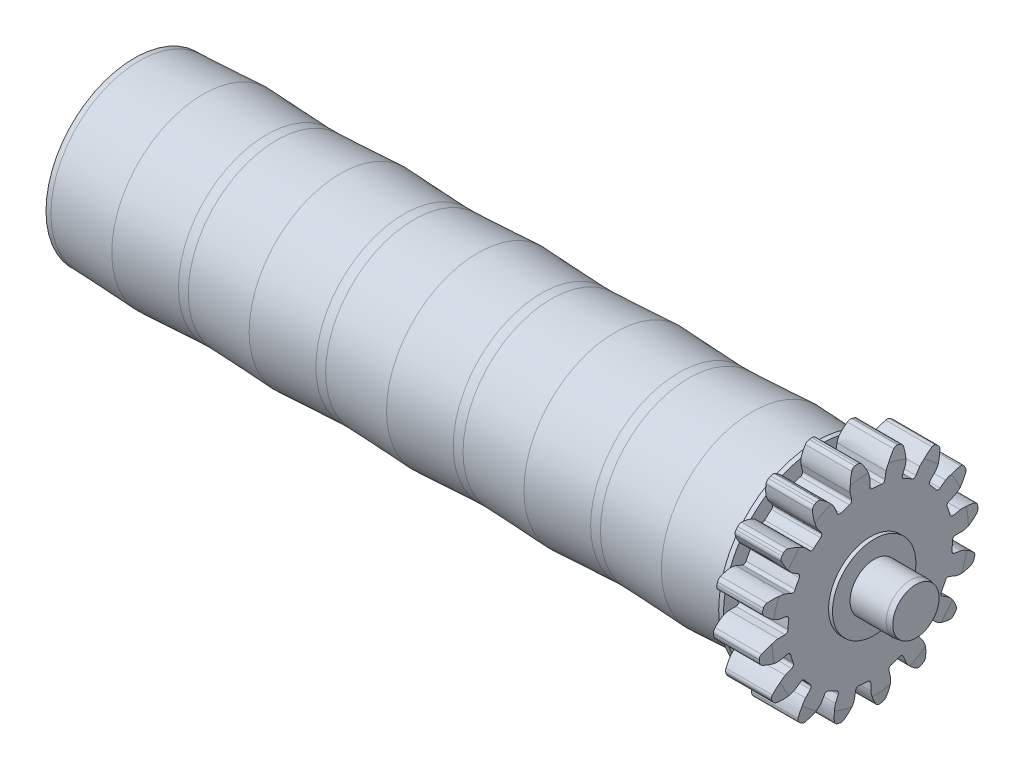
from build123d import *

# Parameters (mm, degrees)
SKETCH1_R                = 20
BOSS_EXTRUDE1_DEPTH      = 150
SKETCH1_3_R              = 8.5
BOSS_EXTRUDE2_DEPTH      = 0.8
BOSS_EXTRUDE3_START      = -0.8
SKETCH1_4_R              = 4.925
BOSS_EXTRUDE3_DEPTH      = 8.5
BOSS_EXTRUDE4_START      = 150
SKETCH1_9_R              = 8.5
SKETCH1_9_R_2            = 4.925
BOSS_EXTRUDE4_DEPTH      = 0.8
BOSS_EXTRUDE5_START      = 150.8
SKETCH1_10_R             = 4.925
BOSS_EXTRUDE5_DEPTH      = 8.5
SKETCH2_W                = 1
SKETCH2_H                = 2
SKETCH3_R                = 22.5
BOSS_EXTRUDE6_DEPTH      = 10
CUT_EXTRUDE3_DEPTH       = 10
FILLET1_R                = 0.5
FILLET2_R                = 1
CIRPATTERN1_COUNT        = 16
FILLET1_OF_CIRPATTERN1_R = 0.5
FILLET2_OF_CIRPATTERN1_R = 1
SKETCH4_OUTSIDE_W        = 82.798
SKETCH4_OUTSIDE_H        = 82.798
CUT_EXTRUDE4_DEPTH       = 10
CHAMFER1_SIZE            = 0.2
CHAMFER1_SIZE2           = 1.134256364
CHAMFER2_SIZE            = 0.2
CHAMFER2_SIZE2           = 1.134256364


with BuildPart() as part:
    # Sketch1 → Boss-Extrude1 (new body)
    with BuildSketch(Plane(origin=(0, 0, 0), x_dir=(0, 0, -1), z_dir=(1, 0, 0))):
        Circle(SKETCH1_R)
    extrude(amount=BOSS_EXTRUDE1_DEPTH)

    # Sketch1_3 → Boss-Extrude2 (add)
    with BuildSketch(Plane(origin=(0, 0, 0), x_dir=(0, 0, -1), z_dir=(1, 0, 0))):
        Circle(SKETCH1_3_R)
    extrude(amount=-BOSS_EXTRUDE2_DEPTH)

    # Sketch1_4 → Boss-Extrude3 (add)
    with BuildSketch(Plane(origin=(0, 0, 0), x_dir=(0, 0, -1), z_dir=(1, 0, 0)).offset(BOSS_EXTRUDE3_START)):
        Circle(SKETCH1_4_R)
    extrude(amount=-BOSS_EXTRUDE3_DEPTH)

    # Sketch1_9 → Boss-Extrude4 (add)
    with BuildSketch(Plane(origin=(0, 0, 0), x_dir=(0, 0, -1), z_dir=(1, 0, 0)).offset(BOSS_EXTRUDE4_START)):
        Circle(SKETCH1_9_R)
        Circle(SKETCH1_9_R_2, mode=Mode.SUBTRACT)
        Circle(SKETCH1_9_R_2)
        with BuildLine():
            ThreePointArc((1.823321146, -2.42), (0, 3.03), (-1.823321146, -2.42))
            ThreePointArc((-1.823321146, -2.42), (0, -3.03), (1.823321146, -2.42))
        make_face(mode=Mode.SUBTRACT)
        with BuildLine():
            Line((-1.823321146, -2.42), (1.823321146, -2.42))
            ThreePointArc((1.823321146, -2.42), (0, 3.03), (-1.823321146, -2.42))
        make_face()
        with BuildLine():
            ThreePointArc((1.823321146, -2.42), (0, -3.03), (-1.823321146, -2.42))
            Line((-1.823321146, -2.42), (1.823321146, -2.42))
        make_face()
    extrude(amount=BOSS_EXTRUDE4_DEPTH)

    # Sketch1_10 → Boss-Extrude5 (add)
    with BuildSketch(Plane(origin=(0, 0, 0), x_dir=(0, 0, -1), z_dir=(1, 0, 0)).offset(BOSS_EXTRUDE5_START)):
        Circle(SKETCH1_10_R)
    extrude(amount=BOSS_EXTRUDE5_DEPTH)

    # Sketch2 → Cut-Revolve1 (revolve, cut)
    with BuildSketch(Plane.XY, mode=Mode.PRIVATE) as cut_revolve1_sk:
        Polygon((27, 20), (1, 20), (1, 18), (14, 18.6), (27, 18), align=None)
        Polygon((27, 18), (27, 20), (28, 20), (29, 20), (29, 18), align=None)
        Polygon((29, 20), (29, 18), (42, 18.6), (55, 18), (55, 20), align=None)
        Polygon((55, 18), (55, 20), (56, 20), (57, 20), (57, 18), align=None)
        Polygon((57, 20), (57, 18), (70, 18.6), (83, 18), (83, 20), align=None)
        Polygon((83, 18), (83, 20), (84, 20), (85, 20), (85, 18), align=None)
        Polygon((85, 20), (85, 18), (98, 18.6), (111, 18), (111, 20), align=None)
        Polygon((111, 18), (111, 20), (112, 20), (113, 20), (113, 18), align=None)
        Polygon((113, 20), (113, 18), (126, 18.6), (139, 18), (139, 19.9), (139, 20), align=None)
        Polygon((140, 20), (139, 20), (139, 19.9), (150, 19.9), (150, 20), align=None)
        with Locations((0.5, 19)):
            Rectangle(SKETCH2_W, SKETCH2_H)
    revolve(cut_revolve1_sk.sketch.rotate(Axis((0, 0, 0), (1, 0, 0)), 90), axis=Axis((0, 0, 0), (1, 0, 0)), mode=Mode.SUBTRACT)  # turned: the seam where the file's is

    # Sketch3 → Boss-Extrude6 (add)
    with BuildSketch(Plane(origin=(150, 0, 0), x_dir=(0, 0, -1), z_dir=(1, 0, 0))):
        Circle(SKETCH3_R)
    extrude(amount=-BOSS_EXTRUDE6_DEPTH)

    # Sketch3_3 → Cut-Extrude3 (cut)
    with BuildSketch(Plane(origin=(150, 0, 0), x_dir=(0, 0, -1), z_dir=(1, 0, 0))):
        with BuildLine():
            Line((18.793852416, 0), (16.875, 0))
            ThreePointArc((16.875, 0), (16.816528534, -1.403564417), (16.641519339, -2.797402201))
            Line((16.641519339, -2.797402201), (18.533822722, -3.11549417))
            add(Edge.make_bspline(
                [(18.533822722, -3.11549417), (18.540143259, -3.116650367), (18.557818877, -3.120174741), (18.59102423, -3.127948355), (18.644868838, -3.14220254), (18.712949139, -3.162664487), (18.800284389, -3.191738795), (18.902266481, -3.229352045), (19.01333304, -3.274191401), (19.133012214, -3.326732031), (19.251334581, -3.382453012), (19.368317547, -3.441093179), (19.483872699, -3.502252085), (19.622639053, -3.579554465), (19.787320314, -3.676709438), (19.977176405, -3.796702318), (20.189293185, -3.940335966), (20.401861332, -4.094683446), (20.60799726, -4.25307101), (20.812611431, -4.420472139), (21.00798126, -4.587659246), (21.20695704, -4.768722867), (21.388624735, -4.939634627), (21.58456819, -5.136136858), (21.702177554, -5.256735347), (21.796059885, -5.357369907), (21.840902155, -5.406014525)],
                knots=[0, 0, 0, 0, 0, 0.005376749, 0.015083688, 0.02853182, 0.04661014, 0.064854849, 0.092110525, 0.119476176, 0.146842496, 0.174208854, 0.201574956, 0.228941013, 0.256307345, 0.307035032, 0.361767352, 0.416499661, 0.471231937, 0.525964282, 0.580696616, 0.635428982, 0.690161387, 0.744893688, 0.799626082, 0.851029126, 0.851029126, 0.851029126, 0.851029126, 0.851029126], degree=4))
            ThreePointArc((21.840902155, -5.406014525), (22.334617732, -2.723022357), (22.5, 0))
            ThreePointArc((22.5, 0), (22.483713995, 0.855923463), (22.434879558, 1.710607852))
            add(Edge.make_bspline(
                [(18.793852416, 0), (18.800277167, 9.2432e-05), (18.81829247, 0.000637921), (18.852327044, 0.002799463), (18.907789609, 0.007930502), (18.978319976, 0.016823532), (19.06926657, 0.031017834), (19.176072873, 0.051204897), (19.293035835, 0.077012138), (19.419768906, 0.108986367), (19.545691155, 0.144321865), (19.670776454, 0.182758195), (19.79487123, 0.223915106), (19.944532197, 0.277144366), (20.123040519, 0.345655574), (20.33016124, 0.432515425), (20.563153629, 0.538998755), (20.798367194, 0.655972857), (21.027907269, 0.777997426), (21.257440837, 0.909163115), (21.477822489, 1.041650195), (21.704060536, 1.187224031), (21.911547079, 1.32565566), (22.137354045, 1.486957173), (22.27332803, 1.586390737), (22.382593806, 1.670069867), (22.434879558, 1.710607852)],
                knots=[0, 0, 0, 0, 0, 0.005376749, 0.015083688, 0.02853182, 0.04661014, 0.064854849, 0.092110525, 0.119476176, 0.146842496, 0.174208854, 0.201574956, 0.228941013, 0.256307345, 0.307035032, 0.361767352, 0.416499661, 0.471231937, 0.525964282, 0.580696616, 0.635428982, 0.690161387, 0.744893688, 0.799626082, 0.851029126, 0.851029126, 0.851029126, 0.851029126, 0.851029126], degree=4))
        make_face()
        with BuildLine():
            Line((18.793852416, 0), (16.875, 0))
            ThreePointArc((16.875, 0), (16.816528534, -1.403564417), (16.641519339, -2.797402201))
            Line((16.641519339, -2.797402201), (18.533822722, -3.11549417))
            add(Edge.make_bspline(
                [(18.533822722, -3.11549417), (18.540143259, -3.116650367), (18.557818877, -3.120174741), (18.59102423, -3.127948355), (18.644868838, -3.14220254), (18.712949139, -3.162664487), (18.800284389, -3.191738795), (18.902266481, -3.229352045), (19.01333304, -3.274191401), (19.133012214, -3.326732031), (19.251334581, -3.382453012), (19.368317547, -3.441093179), (19.483872699, -3.502252085), (19.622639053, -3.579554465), (19.787320314, -3.676709438), (19.977176405, -3.796702318), (20.189293185, -3.940335966), (20.401861332, -4.094683446), (20.60799726, -4.25307101), (20.812611431, -4.420472139), (21.00798126, -4.587659246), (21.20695704, -4.768722867), (21.388624735, -4.939634627), (21.58456819, -5.136136858), (21.702177554, -5.256735347), (21.796059885, -5.357369907), (21.840902155, -5.406014525)],
                knots=[0, 0, 0, 0, 0, 0.005376749, 0.015083688, 0.02853182, 0.04661014, 0.064854849, 0.092110525, 0.119476176, 0.146842496, 0.174208854, 0.201574956, 0.228941013, 0.256307345, 0.307035032, 0.361767352, 0.416499661, 0.471231937, 0.525964282, 0.580696616, 0.635428982, 0.690161387, 0.744893688, 0.799626082, 0.851029126, 0.851029126, 0.851029126, 0.851029126, 0.851029126], degree=4))
            ThreePointArc((21.840902155, -5.406014525), (22.334617732, -2.723022357), (22.5, 0))
            ThreePointArc((22.5, 0), (22.483713995, 0.855923463), (22.434879558, 1.710607852))
            add(Edge.make_bspline(
                [(18.793852416, 0), (18.800277167, 9.2432e-05), (18.81829247, 0.000637921), (18.852327044, 0.002799463), (18.907789609, 0.007930502), (18.978319976, 0.016823532), (19.06926657, 0.031017834), (19.176072873, 0.051204897), (19.293035835, 0.077012138), (19.419768906, 0.108986367), (19.545691155, 0.144321865), (19.670776454, 0.182758195), (19.79487123, 0.223915106), (19.944532197, 0.277144366), (20.123040519, 0.345655574), (20.33016124, 0.432515425), (20.563153629, 0.538998755), (20.798367194, 0.655972857), (21.027907269, 0.777997426), (21.257440837, 0.909163115), (21.477822489, 1.041650195), (21.704060536, 1.187224031), (21.911547079, 1.32565566), (22.137354045, 1.486957173), (22.27332803, 1.586390737), (22.382593806, 1.670069867), (22.434879558, 1.710607852)],
                knots=[0, 0, 0, 0, 0, 0.005376749, 0.015083688, 0.02853182, 0.04661014, 0.064854849, 0.092110525, 0.119476176, 0.146842496, 0.174208854, 0.201574956, 0.228941013, 0.256307345, 0.307035032, 0.361767352, 0.416499661, 0.471231937, 0.525964282, 0.580696616, 0.635428982, 0.690161387, 0.744893688, 0.799626082, 0.851029126, 0.851029126, 0.851029126, 0.851029126, 0.851029126], degree=4))
        make_face()
    cut_extrude3 = extrude(amount=-CUT_EXTRUDE3_DEPTH, mode=Mode.SUBTRACT)

    # Fillet1
    fillet1_edges = [part.edges().sort_by_distance(p)[0] for p in [
        (145, -2.797402201, -16.641519339),
        (145, 0, -16.875),
    ]]
    fillet(fillet1_edges, radius=FILLET1_R)

    # Fillet2
    fillet2_edges = [part.edges().sort_by_distance(p)[0] for p in [
        (145, 1.710607852, -22.434879558),
        (145, -5.406014525, -21.840902155),
    ]]
    fillet(fillet2_edges, radius=FILLET2_R)

    # CirPattern1: Cut-Extrude3 ×16 about axis
    cirpattern1_axis = Axis((126, 0, 0), (-1, 0, 0))
    for i in range(1, CIRPATTERN1_COUNT):
        add(cut_extrude3.rotate(cirpattern1_axis, i * 360 / CIRPATTERN1_COUNT), mode=Mode.SUBTRACT)

    # Fillet1 of CirPattern1
    fillet1_of_cirpattern1_edges = [part.edges().sort_by_distance(p)[0] for p in [
        (145, -8.952896379, -14.304239631),
        (145, -6.457782921, -15.590467111),
        (145, -13.74539324, -9.789269108),
        (145, -11.932426933, -11.932426933),
        (145, -16.445278584, -3.783971103),
        (145, -15.590467111, -6.457782921),
        (145, -16.641519339, 2.797402201),
        (145, -16.875, 0),
        (145, -14.304239631, 8.952896379),
        (145, -15.590467111, 6.457782921),
        (145, -9.789269108, 13.74539324),
        (145, -11.932426933, 11.932426933),
        (145, -3.783971103, 16.445278584),
        (145, -6.457782921, 15.590467111),
        (145, 2.797402201, 16.641519339),
        (145, 0, 16.875),
        (145, 8.952896379, 14.304239631),
        (145, 6.457782921, 15.590467111),
        (145, 13.74539324, 9.789269108),
        (145, 11.932426933, 11.932426933),
        (145, 16.445278584, 3.783971103),
        (145, 15.590467111, 6.457782921),
        (145, 16.641519339, -2.797402201),
        (145, 16.875, 0),
        (145, 14.304239631, -8.952896379),
        (145, 15.590467111, -6.457782921),
        (145, 9.789269108, -13.74539324),
        (145, 11.932426933, -11.932426933),
        (145, 3.783971103, -16.445278584),
        (145, 6.457782921, -15.590467111),
    ]]
    fillet(fillet1_of_cirpattern1_edges, radius=FILLET1_OF_CIRPATTERN1_R)

    # Fillet2 of CirPattern1
    fillet2_of_cirpattern1_edges = [part.edges().sort_by_distance(p)[0] for p in [
        (145, -7.005061131, -21.381747322),
        (145, -13.352657575, -18.109570279),
        (145, -14.654273058, -17.073437883),
        (145, -19.266479551, -11.621220491),
        (145, -20.072504754, -10.165852297),
        (145, -22.247154667, -3.36364523),
        (145, -22.434879558, -1.710607852),
        (145, -21.840902155, 5.406014525),
        (145, -21.381747322, 7.005061131),
        (145, -18.109570279, 13.352657575),
        (145, -17.073437883, 14.654273058),
        (145, -11.621220491, 19.266479551),
        (145, -10.165852297, 20.072504754),
        (145, -3.36364523, 22.247154667),
        (145, -1.710607852, 22.434879558),
        (145, 5.406014525, 21.840902155),
        (145, 7.005061131, 21.381747322),
        (145, 13.352657575, 18.109570279),
        (145, 14.654273058, 17.073437883),
        (145, 19.266479551, 11.621220491),
        (145, 20.072504754, 10.165852297),
        (145, 22.247154667, 3.36364523),
        (145, 22.434879558, 1.710607852),
        (145, 21.840902155, -5.406014525),
        (145, 21.381747322, -7.005061131),
        (145, 18.109570279, -13.352657575),
        (145, 17.073437883, -14.654273058),
        (145, 11.621220491, -19.266479551),
        (145, 10.165852297, -20.072504754),
        (145, 3.36364523, -22.247154667),
    ]]
    fillet(fillet2_of_cirpattern1_edges, radius=FILLET2_OF_CIRPATTERN1_R)

    # Sketch4 outside → Cut-Extrude4 (cut)
    with BuildSketch(Plane(origin=(150, 0, 0), x_dir=(0, 0, -1), z_dir=(1, 0, 0))):
        Rectangle(SKETCH4_OUTSIDE_W, SKETCH4_OUTSIDE_H)
        with BuildLine():
            Line((16.084027229, -6.553982996), (17.400825548, -7.099418718))
            add(Edge.make_bspline(
                [(17.400825548, -7.099418718), (17.468205114, -7.126079363), (17.53735939, -7.143460734), (17.675930951, -7.176848305), (17.745707701, -7.190975003), (17.956070336, -7.22795715), (18.097788211, -7.245382593), (18.52533898, -7.282064664), (18.810706139, -7.285520422), (19.667508071, -7.251758438), (20.232380272, -7.171231176), (20.790500392, -7.047676668)],
                knots=[0, 0, 0, 0, 0.0625, 0.0625, 0.125, 0.125, 0.25, 0.25, 0.5, 0.5, 1, 1, 1, 1], degree=3))
            ThreePointArc((20.790500392, -7.047676668), (21.208669056, -6.828194438), (21.458128433, -6.427186333))
            ThreePointArc((21.458128433, -6.427186333), (21.529993052, -6.182184014), (21.599060408, -5.936378481))
            ThreePointArc((21.599060408, -5.936378481), (21.600355656, -5.464111816), (21.362335917, -5.056209764))
            add(Edge.make_bspline(
                [(21.362335917, -5.056209764), (20.954562332, -4.655146223), (20.516130086, -4.285439291), (19.808296094, -3.802964384), (19.563276919, -3.653961081), (19.184028171, -3.459717512), (19.055472444, -3.399677951), (18.858095781, -3.31961644), (18.79155061, -3.294586267), (18.656290761, -3.249300304), (18.588391332, -3.227250414), (18.516500063, -3.213985271)],
                knots=[0, 0, 0, 0, 0.5, 0.5, 0.75, 0.75, 0.875, 0.875, 0.9375, 0.9375, 1, 1, 1, 1], degree=3))
            Line((18.516500063, -3.213985271), (17.11092802, -2.977711752))
            ThreePointArc((17.11092802, -2.977711752), (16.726725338, -2.741072894), (16.616075542, -2.303618583))
            ThreePointArc((16.616075542, -2.303618583), (16.716875031, -1.395246999), (16.768052751, -0.482733813))
            ThreePointArc((16.768052751, -0.482733813), (16.949689277, -0.069674709), (17.367804265, 0.1))
            Line((17.367804265, 0.1), (18.793096495, 0.1))
            add(Edge.make_bspline(
                [(18.793096495, 0.1), (18.865549684, 0.10115382), (18.936091467, 0.111559723), (19.076891767, 0.13374267), (19.146763131, 0.147393709), (19.355265319, 0.193728955), (19.492863991, 0.231863028), (19.901907017, 0.361589809), (20.166874355, 0.467602389), (20.945535972, 0.826678299), (21.436593388, 1.117243022), (21.904946881, 1.444975825)],
                knots=[0, 0, 0, 0, 0.0625, 0.0625, 0.125, 0.125, 0.25, 0.25, 0.5, 0.5, 1, 1, 1, 1], degree=3))
            ThreePointArc((21.904946881, 1.444975825), (22.207292137, 1.807777185), (22.284303392, 2.273724336))
            ThreePointArc((22.284303392, 2.273724336), (22.256939314, 2.527578363), (22.226683526, 2.781103997))
            ThreePointArc((22.226683526, 2.781103997), (22.04715155, 3.217917173), (21.671152627, 3.503683319))
            add(Edge.make_bspline(
                [(21.671152627, 3.503683319), (21.140938586, 3.718169521), (20.59439929, 3.891953432), (19.755810799, 4.066825781), (19.472421503, 4.110722104), (19.047707551, 4.145047549), (18.905961401, 4.151320724), (18.692970927, 4.149755137), (18.621912574, 4.147414267), (18.47961858, 4.137491338), (18.40844956, 4.131878793), (18.336954337, 4.11662259)],
                knots=[0, 0, 0, 0, 0.5, 0.5, 0.75, 0.75, 0.875, 0.875, 0.9375, 0.9375, 1, 1, 1, 1], degree=3))
            Line((18.336954337, 4.11662259), (16.947957134, 3.797021724))
            ThreePointArc((16.947957134, 3.797021724), (16.502442369, 3.868619521), (16.23280877, 4.230430761))
            ThreePointArc((16.23280877, 4.230430761), (15.978316599, 5.108230971), (15.676394969, 5.970868091))
            ThreePointArc((15.676394969, 5.970868091), (15.686134362, 6.421994232), (16.007490542, 6.738758902))
            Line((16.007490542, 6.738758902), (17.324288861, 7.284194625))
            add(Edge.make_bspline(
                [(17.324288861, 7.284194625), (17.390785332, 7.31298725), (17.451975275, 7.349596223), (17.573568743, 7.423972535), (17.63289744, 7.463323064), (17.807796613, 7.585921583), (17.920327932, 7.673809605), (18.248590122, 7.950195511), (18.452818764, 8.149536975), (19.034795893, 8.779260759), (19.377279484, 9.235627096), (19.684563776, 9.717643848)],
                knots=[0, 0, 0, 0, 0.0625, 0.0625, 0.125, 0.125, 0.25, 0.25, 0.5, 0.5, 1, 1, 1, 1], degree=3))
            ThreePointArc((19.684563776, 9.717643848), (19.8250563, 10.168531119), (19.717895167, 10.628481086))
            ThreePointArc((19.717895167, 10.628481086), (19.595468325, 10.852539847), (19.470495562, 11.075188602))
            ThreePointArc((19.470495562, 11.075188602), (19.137468479, 11.410047442), (18.6807328, 11.530172378))
            add(Edge.make_bspline(
                [(18.6807328, 11.530172378), (18.108798583, 11.525427661), (17.537357891, 11.476831525), (16.695682397, 11.317478587), (16.41706643, 11.249585113), (16.011546124, 11.118766696), (15.878189117, 11.070318451), (15.682010702, 10.987364112), (15.617257156, 10.958008575), (15.489591988, 10.89438743), (15.425988215, 10.86196691), (15.365773538, 10.820511979)],
                knots=[0, 0, 0, 0, 0.5, 0.5, 0.75, 0.75, 0.875, 0.875, 0.9375, 0.9375, 1, 1, 1, 1], degree=3))
            Line((15.365773538, 10.820511979), (14.204813408, 9.993693063))
            ThreePointArc((14.204813408, 9.993693063), (13.765812144, 9.889349683), (13.378244014, 10.120435371))
            ThreePointArc((13.378244014, 10.120435371), (12.807204309, 10.834027081), (12.19814816, 11.515459455))
            ThreePointArc((12.19814816, 11.515459455), (12.034507686, 11.935972767), (12.210181492, 12.351602848))
            Line((12.210181492, 12.351602848), (13.218015293, 13.35943665))
            add(Edge.make_bspline(
                [(13.218015293, 13.35943665), (13.26843156, 13.411484664), (13.310954049, 13.468723322), (13.394829183, 13.583969881), (13.434582957, 13.643029139), (13.549252301, 13.823226417), (13.619584394, 13.947488232), (13.817090804, 14.328456016), (13.929488792, 14.590778432), (14.22618069, 15.395280352), (14.367950434, 15.947970667), (14.467384276, 16.510888685)],
                knots=[0, 0, 0, 0, 0.0625, 0.0625, 0.125, 0.125, 0.25, 0.25, 0.5, 0.5, 1, 1, 1, 1], degree=3))
            ThreePointArc((14.467384276, 16.510888685), (14.424635355, 16.981218368), (14.149616146, 17.365147939))
            ThreePointArc((14.149616146, 17.365147939), (13.950764917, 17.525300518), (13.750101149, 17.68317614))
            ThreePointArc((13.750101149, 17.68317614), (13.314279313, 17.865101421), (12.846340745, 17.801297213))
            add(Edge.make_bspline(
                [(12.846340745, 17.801297213), (12.319758153, 17.578043917), (11.810412729, 17.314466056), (11.093787696, 16.845147872), (10.862361815, 16.675800766), (10.537771945, 16.399754405), (10.433106477, 16.303960546), (10.283606506, 16.152246501), (10.235015907, 16.100345412), (10.141415429, 15.992711794), (10.095060001, 15.938419029), (10.055293009, 15.877076507)],
                knots=[0, 0, 0, 0, 0.5, 0.5, 0.75, 0.75, 0.875, 0.875, 0.9375, 0.9375, 1, 1, 1, 1], degree=3))
            Line((10.055293009, 15.877076507), (9.299115607, 14.668915226))
            ThreePointArc((9.299115607, 14.668915226), (8.933461808, 14.404516002), (8.486962881, 14.469695438))
            ThreePointArc((8.486962881, 14.469695438), (7.68631126, 14.910440779), (6.86284387, 15.306926504))
            ThreePointArc((6.86284387, 15.306926504), (6.550736307, 15.632807648), (6.553982996, 16.084027229))
            Line((6.553982996, 16.084027229), (7.099418718, 17.400825548))
            add(Edge.make_bspline(
                [(7.099418718, 17.400825548), (7.126079363, 17.468205114), (7.143460734, 17.53735939), (7.176848305, 17.675930951), (7.190975003, 17.745707701), (7.22795715, 17.956070336), (7.245382593, 18.097788211), (7.282064664, 18.52533898), (7.285520422, 18.810706139), (7.251758438, 19.667508071), (7.171231176, 20.232380272), (7.047676668, 20.790500392)],
                knots=[0, 0, 0, 0, 0.0625, 0.0625, 0.125, 0.125, 0.25, 0.25, 0.5, 0.5, 1, 1, 1, 1], degree=3))
            ThreePointArc((7.047676668, 20.790500392), (6.828194438, 21.208669056), (6.427186333, 21.458128433))
            ThreePointArc((6.427186333, 21.458128433), (6.182184014, 21.529993052), (5.936378481, 21.599060408))
            ThreePointArc((5.936378481, 21.599060408), (5.464111816, 21.600355656), (5.056209764, 21.362335917))
            add(Edge.make_bspline(
                [(5.056209764, 21.362335917), (4.655146223, 20.954562332), (4.285439291, 20.516130086), (3.802964384, 19.808296094), (3.653961081, 19.563276919), (3.459717512, 19.184028171), (3.399677951, 19.055472444), (3.31961644, 18.858095781), (3.294586267, 18.79155061), (3.249300304, 18.656290761), (3.227250414, 18.588391332), (3.213985271, 18.516500063)],
                knots=[0, 0, 0, 0, 0.5, 0.5, 0.75, 0.75, 0.875, 0.875, 0.9375, 0.9375, 1, 1, 1, 1], degree=3))
            Line((3.213985271, 18.516500063), (2.977711752, 17.11092802))
            ThreePointArc((2.977711752, 17.11092802), (2.741072894, 16.726725338), (2.303618583, 16.616075542))
            ThreePointArc((2.303618583, 16.616075542), (1.395246999, 16.716875031), (0.482733813, 16.768052751))
            ThreePointArc((0.482733813, 16.768052751), (0.069674709, 16.949689277), (-0.1, 17.367804265))
            Line((-0.1, 17.367804265), (-0.1, 18.793096495))
            add(Edge.make_bspline(
                [(-0.1, 18.793096495), (-0.10115382, 18.865549684), (-0.111559723, 18.936091467), (-0.13374267, 19.076891767), (-0.147393709, 19.146763131), (-0.193728955, 19.355265319), (-0.231863028, 19.492863991), (-0.361589809, 19.901907017), (-0.467602389, 20.166874355), (-0.826678299, 20.945535972), (-1.117243022, 21.436593388), (-1.444975825, 21.904946881)],
                knots=[0, 0, 0, 0, 0.0625, 0.0625, 0.125, 0.125, 0.25, 0.25, 0.5, 0.5, 1, 1, 1, 1], degree=3))
            ThreePointArc((-1.444975825, 21.904946881), (-1.807777185, 22.207292137), (-2.273724336, 22.284303392))
            ThreePointArc((-2.273724336, 22.284303392), (-2.527578363, 22.256939314), (-2.781103997, 22.226683526))
            ThreePointArc((-2.781103997, 22.226683526), (-3.217917173, 22.04715155), (-3.503683319, 21.671152627))
            add(Edge.make_bspline(
                [(-3.503683319, 21.671152627), (-3.718169521, 21.140938586), (-3.891953432, 20.59439929), (-4.066825781, 19.755810799), (-4.110722104, 19.472421503), (-4.145047549, 19.047707551), (-4.151320724, 18.905961401), (-4.149755137, 18.692970927), (-4.147414267, 18.621912574), (-4.137491338, 18.47961858), (-4.131878793, 18.40844956), (-4.11662259, 18.336954337)],
                knots=[0, 0, 0, 0, 0.5, 0.5, 0.75, 0.75, 0.875, 0.875, 0.9375, 0.9375, 1, 1, 1, 1], degree=3))
            Line((-4.11662259, 18.336954337), (-3.797021724, 16.947957134))
            ThreePointArc((-3.797021724, 16.947957134), (-3.868619521, 16.502442369), (-4.230430761, 16.23280877))
            ThreePointArc((-4.230430761, 16.23280877), (-5.108230971, 15.978316599), (-5.970868091, 15.676394969))
            ThreePointArc((-5.970868091, 15.676394969), (-6.421994232, 15.686134362), (-6.738758902, 16.007490542))
            Line((-6.738758902, 16.007490542), (-7.284194625, 17.324288861))
            add(Edge.make_bspline(
                [(-7.284194625, 17.324288861), (-7.31298725, 17.390785332), (-7.349596223, 17.451975275), (-7.423972535, 17.573568743), (-7.463323064, 17.63289744), (-7.585921583, 17.807796613), (-7.673809605, 17.920327932), (-7.950195511, 18.248590122), (-8.149536975, 18.452818764), (-8.779260759, 19.034795893), (-9.235627096, 19.377279484), (-9.717643848, 19.684563776)],
                knots=[0, 0, 0, 0, 0.0625, 0.0625, 0.125, 0.125, 0.25, 0.25, 0.5, 0.5, 1, 1, 1, 1], degree=3))
            ThreePointArc((-9.717643848, 19.684563776), (-10.168531119, 19.8250563), (-10.628481086, 19.717895167))
            ThreePointArc((-10.628481086, 19.717895167), (-10.852539847, 19.595468325), (-11.075188602, 19.470495562))
            ThreePointArc((-11.075188602, 19.470495562), (-11.410047442, 19.137468479), (-11.530172378, 18.6807328))
            add(Edge.make_bspline(
                [(-11.530172378, 18.6807328), (-11.525427661, 18.108798583), (-11.476831525, 17.537357891), (-11.317478587, 16.695682397), (-11.249585113, 16.41706643), (-11.118766696, 16.011546124), (-11.070318451, 15.878189117), (-10.987364112, 15.682010702), (-10.958008575, 15.617257156), (-10.89438743, 15.489591988), (-10.86196691, 15.425988215), (-10.820511979, 15.365773538)],
                knots=[0, 0, 0, 0, 0.5, 0.5, 0.75, 0.75, 0.875, 0.875, 0.9375, 0.9375, 1, 1, 1, 1], degree=3))
            Line((-10.820511979, 15.365773538), (-9.993693063, 14.204813408))
            ThreePointArc((-9.993693063, 14.204813408), (-9.889349683, 13.765812144), (-10.120435371, 13.378244014))
            ThreePointArc((-10.120435371, 13.378244014), (-10.834027081, 12.807204309), (-11.515459455, 12.19814816))
            ThreePointArc((-11.515459455, 12.19814816), (-11.935972767, 12.034507686), (-12.351602848, 12.210181492))
            Line((-12.351602848, 12.210181492), (-13.35943665, 13.218015293))
            add(Edge.make_bspline(
                [(-13.35943665, 13.218015293), (-13.411484664, 13.26843156), (-13.468723322, 13.310954049), (-13.583969881, 13.394829183), (-13.643029139, 13.434582957), (-13.823226417, 13.549252301), (-13.947488232, 13.619584394), (-14.328456016, 13.817090804), (-14.590778432, 13.929488792), (-15.395280352, 14.22618069), (-15.947970667, 14.367950434), (-16.510888685, 14.467384276)],
                knots=[0, 0, 0, 0, 0.0625, 0.0625, 0.125, 0.125, 0.25, 0.25, 0.5, 0.5, 1, 1, 1, 1], degree=3))
            ThreePointArc((-16.510888685, 14.467384276), (-16.981218368, 14.424635355), (-17.365147939, 14.149616146))
            ThreePointArc((-17.365147939, 14.149616146), (-17.525300518, 13.950764917), (-17.68317614, 13.750101149))
            ThreePointArc((-17.68317614, 13.750101149), (-17.865101421, 13.314279313), (-17.801297213, 12.846340745))
            add(Edge.make_bspline(
                [(-17.801297213, 12.846340745), (-17.578043917, 12.319758153), (-17.314466056, 11.810412729), (-16.845147872, 11.093787696), (-16.675800766, 10.862361815), (-16.399754405, 10.537771945), (-16.303960546, 10.433106477), (-16.152246501, 10.283606506), (-16.100345412, 10.235015907), (-15.992711794, 10.141415429), (-15.938419029, 10.095060001), (-15.877076507, 10.055293009)],
                knots=[0, 0, 0, 0, 0.5, 0.5, 0.75, 0.75, 0.875, 0.875, 0.9375, 0.9375, 1, 1, 1, 1], degree=3))
            Line((-15.877076507, 10.055293009), (-14.668915226, 9.299115607))
            ThreePointArc((-14.668915226, 9.299115607), (-14.404516002, 8.933461808), (-14.469695438, 8.486962881))
            ThreePointArc((-14.469695438, 8.486962881), (-14.910440779, 7.68631126), (-15.306926504, 6.86284387))
            ThreePointArc((-15.306926504, 6.86284387), (-15.632807648, 6.550736307), (-16.084027229, 6.553982996))
            Line((-16.084027229, 6.553982996), (-17.400825548, 7.099418718))
            add(Edge.make_bspline(
                [(-17.400825548, 7.099418718), (-17.468205114, 7.126079363), (-17.53735939, 7.143460734), (-17.675930951, 7.176848305), (-17.745707701, 7.190975003), (-17.956070336, 7.22795715), (-18.097788211, 7.245382593), (-18.52533898, 7.282064664), (-18.810706139, 7.285520422), (-19.667508071, 7.251758438), (-20.232380272, 7.171231176), (-20.790500392, 7.047676668)],
                knots=[0, 0, 0, 0, 0.0625, 0.0625, 0.125, 0.125, 0.25, 0.25, 0.5, 0.5, 1, 1, 1, 1], degree=3))
            ThreePointArc((-20.790500392, 7.047676668), (-21.208669056, 6.828194438), (-21.458128433, 6.427186333))
            ThreePointArc((-21.458128433, 6.427186333), (-21.529993052, 6.182184014), (-21.599060408, 5.936378481))
            ThreePointArc((-21.599060408, 5.936378481), (-21.600355656, 5.464111816), (-21.362335917, 5.056209764))
            add(Edge.make_bspline(
                [(-21.362335917, 5.056209764), (-20.954562332, 4.655146223), (-20.516130086, 4.285439291), (-19.808296094, 3.802964384), (-19.563276919, 3.653961081), (-19.184028171, 3.459717512), (-19.055472444, 3.399677951), (-18.858095781, 3.31961644), (-18.79155061, 3.294586267), (-18.656290761, 3.249300304), (-18.588391332, 3.227250414), (-18.516500063, 3.213985271)],
                knots=[0, 0, 0, 0, 0.5, 0.5, 0.75, 0.75, 0.875, 0.875, 0.9375, 0.9375, 1, 1, 1, 1], degree=3))
            Line((-18.516500063, 3.213985271), (-17.11092802, 2.977711752))
            ThreePointArc((-17.11092802, 2.977711752), (-16.726725338, 2.741072894), (-16.616075542, 2.303618583))
            ThreePointArc((-16.616075542, 2.303618583), (-16.716875031, 1.395246999), (-16.768052751, 0.482733813))
            ThreePointArc((-16.768052751, 0.482733813), (-16.949689277, 0.069674709), (-17.367804265, -0.1))
            Line((-17.367804265, -0.1), (-18.793096495, -0.1))
            add(Edge.make_bspline(
                [(-18.793096495, -0.1), (-18.865549684, -0.10115382), (-18.936091467, -0.111559723), (-19.076891767, -0.13374267), (-19.146763131, -0.147393709), (-19.355265319, -0.193728955), (-19.492863991, -0.231863028), (-19.901907017, -0.361589809), (-20.166874355, -0.467602389), (-20.945535972, -0.826678299), (-21.436593388, -1.117243022), (-21.904946881, -1.444975825)],
                knots=[0, 0, 0, 0, 0.0625, 0.0625, 0.125, 0.125, 0.25, 0.25, 0.5, 0.5, 1, 1, 1, 1], degree=3))
            ThreePointArc((-21.904946881, -1.444975825), (-22.207292137, -1.807777185), (-22.284303392, -2.273724336))
            ThreePointArc((-22.284303392, -2.273724336), (-22.256939314, -2.527578363), (-22.226683526, -2.781103997))
            ThreePointArc((-22.226683526, -2.781103997), (-22.04715155, -3.217917173), (-21.671152627, -3.503683319))
            add(Edge.make_bspline(
                [(-21.671152627, -3.503683319), (-21.140938586, -3.718169521), (-20.59439929, -3.891953432), (-19.755810799, -4.066825781), (-19.472421503, -4.110722104), (-19.047707551, -4.145047549), (-18.905961401, -4.151320724), (-18.692970927, -4.149755137), (-18.621912574, -4.147414267), (-18.47961858, -4.137491338), (-18.40844956, -4.131878793), (-18.336954337, -4.11662259)],
                knots=[0, 0, 0, 0, 0.5, 0.5, 0.75, 0.75, 0.875, 0.875, 0.9375, 0.9375, 1, 1, 1, 1], degree=3))
            Line((-18.336954337, -4.11662259), (-16.947957134, -3.797021724))
            ThreePointArc((-16.947957134, -3.797021724), (-16.502442369, -3.868619521), (-16.23280877, -4.230430761))
            ThreePointArc((-16.23280877, -4.230430761), (-15.978316599, -5.108230971), (-15.676394969, -5.970868091))
            ThreePointArc((-15.676394969, -5.970868091), (-15.686134362, -6.421994232), (-16.007490542, -6.738758902))
            Line((-16.007490542, -6.738758902), (-17.324288861, -7.284194625))
            add(Edge.make_bspline(
                [(-17.324288861, -7.284194625), (-17.390785332, -7.31298725), (-17.451975275, -7.349596223), (-17.573568743, -7.423972535), (-17.63289744, -7.463323064), (-17.807796613, -7.585921583), (-17.920327932, -7.673809605), (-18.248590122, -7.950195511), (-18.452818764, -8.149536975), (-19.034795893, -8.779260759), (-19.377279484, -9.235627096), (-19.684563776, -9.717643848)],
                knots=[0, 0, 0, 0, 0.0625, 0.0625, 0.125, 0.125, 0.25, 0.25, 0.5, 0.5, 1, 1, 1, 1], degree=3))
            ThreePointArc((-19.684563776, -9.717643848), (-19.8250563, -10.168531119), (-19.717895167, -10.628481086))
            ThreePointArc((-19.717895167, -10.628481086), (-19.595468325, -10.852539847), (-19.470495562, -11.075188602))
            ThreePointArc((-19.470495562, -11.075188602), (-19.137468479, -11.410047442), (-18.6807328, -11.530172378))
            add(Edge.make_bspline(
                [(-18.6807328, -11.530172378), (-18.108798583, -11.525427661), (-17.537357891, -11.476831525), (-16.695682397, -11.317478587), (-16.41706643, -11.249585113), (-16.011546124, -11.118766696), (-15.878189117, -11.070318451), (-15.682010702, -10.987364112), (-15.617257156, -10.958008575), (-15.489591988, -10.89438743), (-15.425988215, -10.86196691), (-15.365773538, -10.820511979)],
                knots=[0, 0, 0, 0, 0.5, 0.5, 0.75, 0.75, 0.875, 0.875, 0.9375, 0.9375, 1, 1, 1, 1], degree=3))
            Line((-15.365773538, -10.820511979), (-14.204813408, -9.993693063))
            ThreePointArc((-14.204813408, -9.993693063), (-13.765812144, -9.889349683), (-13.378244014, -10.120435371))
            ThreePointArc((-13.378244014, -10.120435371), (-12.807204309, -10.834027081), (-12.19814816, -11.515459455))
            ThreePointArc((-12.19814816, -11.515459455), (-12.034507686, -11.935972767), (-12.210181492, -12.351602848))
            Line((-12.210181492, -12.351602848), (-13.218015293, -13.35943665))
            add(Edge.make_bspline(
                [(-13.218015293, -13.35943665), (-13.26843156, -13.411484664), (-13.310954049, -13.468723322), (-13.394829183, -13.583969881), (-13.434582957, -13.643029139), (-13.549252301, -13.823226417), (-13.619584394, -13.947488232), (-13.817090804, -14.328456016), (-13.929488792, -14.590778432), (-14.22618069, -15.395280352), (-14.367950434, -15.947970667), (-14.467384276, -16.510888685)],
                knots=[0, 0, 0, 0, 0.0625, 0.0625, 0.125, 0.125, 0.25, 0.25, 0.5, 0.5, 1, 1, 1, 1], degree=3))
            ThreePointArc((-14.467384276, -16.510888685), (-14.424635355, -16.981218368), (-14.149616146, -17.365147939))
            ThreePointArc((-14.149616146, -17.365147939), (-13.950764917, -17.525300518), (-13.750101149, -17.68317614))
            ThreePointArc((-13.750101149, -17.68317614), (-13.314279313, -17.865101421), (-12.846340745, -17.801297213))
            add(Edge.make_bspline(
                [(-12.846340745, -17.801297213), (-12.319758153, -17.578043917), (-11.810412729, -17.314466056), (-11.093787696, -16.845147872), (-10.862361815, -16.675800766), (-10.537771945, -16.399754405), (-10.433106477, -16.303960546), (-10.283606506, -16.152246501), (-10.235015907, -16.100345412), (-10.141415429, -15.992711794), (-10.095060001, -15.938419029), (-10.055293009, -15.877076507)],
                knots=[0, 0, 0, 0, 0.5, 0.5, 0.75, 0.75, 0.875, 0.875, 0.9375, 0.9375, 1, 1, 1, 1], degree=3))
            Line((-10.055293009, -15.877076507), (-9.299115607, -14.668915226))
            ThreePointArc((-9.299115607, -14.668915226), (-8.933461808, -14.404516002), (-8.486962881, -14.469695438))
            ThreePointArc((-8.486962881, -14.469695438), (-7.68631126, -14.910440779), (-6.86284387, -15.306926504))
            ThreePointArc((-6.86284387, -15.306926504), (-6.550736307, -15.632807648), (-6.553982996, -16.084027229))
            Line((-6.553982996, -16.084027229), (-7.099418718, -17.400825548))
            add(Edge.make_bspline(
                [(-7.099418718, -17.400825548), (-7.126079363, -17.468205114), (-7.143460734, -17.53735939), (-7.176848305, -17.675930951), (-7.190975003, -17.745707701), (-7.22795715, -17.956070336), (-7.245382593, -18.097788211), (-7.282064664, -18.52533898), (-7.285520422, -18.810706139), (-7.251758438, -19.667508071), (-7.171231176, -20.232380272), (-7.047676668, -20.790500392)],
                knots=[0, 0, 0, 0, 0.0625, 0.0625, 0.125, 0.125, 0.25, 0.25, 0.5, 0.5, 1, 1, 1, 1], degree=3))
            ThreePointArc((-7.047676668, -20.790500392), (-6.828194438, -21.208669056), (-6.427186333, -21.458128433))
            ThreePointArc((-6.427186333, -21.458128433), (-6.182184014, -21.529993052), (-5.936378481, -21.599060408))
            ThreePointArc((-5.936378481, -21.599060408), (-5.464111816, -21.600355656), (-5.056209764, -21.362335917))
            add(Edge.make_bspline(
                [(-5.056209764, -21.362335917), (-4.655146223, -20.954562332), (-4.285439291, -20.516130086), (-3.802964384, -19.808296094), (-3.653961081, -19.563276919), (-3.459717512, -19.184028171), (-3.399677951, -19.055472444), (-3.31961644, -18.858095781), (-3.294586267, -18.79155061), (-3.249300304, -18.656290761), (-3.227250414, -18.588391332), (-3.213985271, -18.516500063)],
                knots=[0, 0, 0, 0, 0.5, 0.5, 0.75, 0.75, 0.875, 0.875, 0.9375, 0.9375, 1, 1, 1, 1], degree=3))
            Line((-3.213985271, -18.516500063), (-2.977711752, -17.11092802))
            ThreePointArc((-2.977711752, -17.11092802), (-2.741072894, -16.726725338), (-2.303618583, -16.616075542))
            ThreePointArc((-2.303618583, -16.616075542), (-1.395246999, -16.716875031), (-0.482733813, -16.768052751))
            ThreePointArc((-0.482733813, -16.768052751), (-0.069674709, -16.949689277), (0.1, -17.367804265))
            Line((0.1, -17.367804265), (0.1, -18.793096495))
            add(Edge.make_bspline(
                [(0.1, -18.793096495), (0.10115382, -18.865549684), (0.111559723, -18.936091467), (0.13374267, -19.076891767), (0.147393709, -19.146763131), (0.193728955, -19.355265319), (0.231863028, -19.492863991), (0.361589809, -19.901907017), (0.467602389, -20.166874355), (0.826678299, -20.945535972), (1.117243022, -21.436593388), (1.444975825, -21.904946881)],
                knots=[0, 0, 0, 0, 0.0625, 0.0625, 0.125, 0.125, 0.25, 0.25, 0.5, 0.5, 1, 1, 1, 1], degree=3))
            ThreePointArc((1.444975825, -21.904946881), (1.807777185, -22.207292137), (2.273724336, -22.284303392))
            ThreePointArc((2.273724336, -22.284303392), (2.527578363, -22.256939314), (2.781103997, -22.226683526))
            ThreePointArc((2.781103997, -22.226683526), (3.217917173, -22.04715155), (3.503683319, -21.671152627))
            add(Edge.make_bspline(
                [(3.503683319, -21.671152627), (3.718169521, -21.140938586), (3.891953432, -20.59439929), (4.066825781, -19.755810799), (4.110722104, -19.472421503), (4.145047549, -19.047707551), (4.151320724, -18.905961401), (4.149755137, -18.692970927), (4.147414267, -18.621912574), (4.137491338, -18.47961858), (4.131878793, -18.40844956), (4.11662259, -18.336954337)],
                knots=[0, 0, 0, 0, 0.5, 0.5, 0.75, 0.75, 0.875, 0.875, 0.9375, 0.9375, 1, 1, 1, 1], degree=3))
            Line((4.11662259, -18.336954337), (3.797021724, -16.947957134))
            ThreePointArc((3.797021724, -16.947957134), (3.868619521, -16.502442369), (4.230430761, -16.23280877))
            ThreePointArc((4.230430761, -16.23280877), (5.108230971, -15.978316599), (5.970868091, -15.676394969))
            ThreePointArc((5.970868091, -15.676394969), (6.421994232, -15.686134362), (6.738758902, -16.007490542))
            Line((6.738758902, -16.007490542), (7.284194625, -17.324288861))
            add(Edge.make_bspline(
                [(7.284194625, -17.324288861), (7.31298725, -17.390785332), (7.349596223, -17.451975275), (7.423972535, -17.573568743), (7.463323064, -17.63289744), (7.585921583, -17.807796613), (7.673809605, -17.920327932), (7.950195511, -18.248590122), (8.149536975, -18.452818764), (8.779260759, -19.034795893), (9.235627096, -19.377279484), (9.717643848, -19.684563776)],
                knots=[0, 0, 0, 0, 0.0625, 0.0625, 0.125, 0.125, 0.25, 0.25, 0.5, 0.5, 1, 1, 1, 1], degree=3))
            ThreePointArc((9.717643848, -19.684563776), (10.168531119, -19.8250563), (10.628481086, -19.717895167))
            ThreePointArc((10.628481086, -19.717895167), (10.852539847, -19.595468325), (11.075188602, -19.470495562))
            ThreePointArc((11.075188602, -19.470495562), (11.410047442, -19.137468479), (11.530172378, -18.6807328))
            add(Edge.make_bspline(
                [(11.530172378, -18.6807328), (11.525427661, -18.108798583), (11.476831525, -17.537357891), (11.317478587, -16.695682397), (11.249585113, -16.41706643), (11.118766696, -16.011546124), (11.070318451, -15.878189117), (10.987364112, -15.682010702), (10.958008575, -15.617257156), (10.89438743, -15.489591988), (10.86196691, -15.425988215), (10.820511979, -15.365773538)],
                knots=[0, 0, 0, 0, 0.5, 0.5, 0.75, 0.75, 0.875, 0.875, 0.9375, 0.9375, 1, 1, 1, 1], degree=3))
            Line((10.820511979, -15.365773538), (9.993693063, -14.204813408))
            ThreePointArc((9.993693063, -14.204813408), (9.889349683, -13.765812144), (10.120435371, -13.378244014))
            ThreePointArc((10.120435371, -13.378244014), (10.834027081, -12.807204309), (11.515459455, -12.19814816))
            ThreePointArc((11.515459455, -12.19814816), (11.935972767, -12.034507686), (12.351602848, -12.210181492))
            Line((12.351602848, -12.210181492), (13.35943665, -13.218015293))
            add(Edge.make_bspline(
                [(13.35943665, -13.218015293), (13.411484664, -13.26843156), (13.468723322, -13.310954049), (13.583969881, -13.394829183), (13.643029139, -13.434582957), (13.823226417, -13.549252301), (13.947488232, -13.619584394), (14.328456016, -13.817090804), (14.590778432, -13.929488792), (15.395280352, -14.22618069), (15.947970667, -14.367950434), (16.510888685, -14.467384276)],
                knots=[0, 0, 0, 0, 0.0625, 0.0625, 0.125, 0.125, 0.25, 0.25, 0.5, 0.5, 1, 1, 1, 1], degree=3))
            ThreePointArc((16.510888685, -14.467384276), (16.981218368, -14.424635355), (17.365147939, -14.149616146))
            ThreePointArc((17.365147939, -14.149616146), (17.525300518, -13.950764917), (17.68317614, -13.750101149))
            ThreePointArc((17.68317614, -13.750101149), (17.865101421, -13.314279313), (17.801297213, -12.846340745))
            add(Edge.make_bspline(
                [(17.801297213, -12.846340745), (17.578043917, -12.319758153), (17.314466056, -11.810412729), (16.845147872, -11.093787696), (16.675800766, -10.862361815), (16.399754405, -10.537771945), (16.303960546, -10.433106477), (16.152246501, -10.283606506), (16.100345412, -10.235015907), (15.992711794, -10.141415429), (15.938419029, -10.095060001), (15.877076507, -10.055293009)],
                knots=[0, 0, 0, 0, 0.5, 0.5, 0.75, 0.75, 0.875, 0.875, 0.9375, 0.9375, 1, 1, 1, 1], degree=3))
            Line((15.877076507, -10.055293009), (14.668915226, -9.299115607))
            ThreePointArc((14.668915226, -9.299115607), (14.404516002, -8.933461808), (14.469695438, -8.486962881))
            ThreePointArc((14.469695438, -8.486962881), (14.910440779, -7.68631126), (15.306926504, -6.86284387))
            ThreePointArc((15.306926504, -6.86284387), (15.632807648, -6.550736307), (16.084027229, -6.553982996))
        make_face(mode=Mode.SUBTRACT)
    extrude(amount=-CUT_EXTRUDE4_DEPTH, mode=Mode.SUBTRACT)

    # Sketch5 → Cut-Revolve2 (revolve, cut)
    with BuildSketch(Plane(origin=(0, 0, 0), x_dir=(1, 0, 0), z_dir=(0, 1, 0)), mode=Mode.PRIVATE) as cut_revolve2_sk:
        Polygon((154.79784495, 8.5), (150, 8.5), (150, 20), (149.648647913, 22.5), (140.351352087, 22.5), (140, 20), (140, 27.064455734), (154.79784495, 27.064455734), align=None)
    revolve(cut_revolve2_sk.sketch.rotate(Axis((159.3, 0, 0), (-1, 0, 0)), 180), axis=Axis((159.3, 0, 0), (-1, 0, 0)), mode=Mode.SUBTRACT)  # turned: the seam where the file's is

    # Chamfer1
    chamfer1_edges = [part.edges().sort_by_distance(p)[0] for p in [
        (159.3, 0, 4.925),
    ]]
    chamfer1_side = [part.faces().sort_by_distance(p)[0] for p in [
        (159.3, 0, 0),
    ]]
    chamfer(chamfer1_edges, length=CHAMFER1_SIZE, length2=CHAMFER1_SIZE2, reference=chamfer1_side[0])

    # Chamfer2
    chamfer2_edges = [part.edges().sort_by_distance(p)[0] for p in [
        (-9.3, 0, 4.925),
    ]]
    chamfer2_side = [part.faces().sort_by_distance(p)[0] for p in [
        (-9.3, 0, 0),
    ]]
    chamfer(chamfer2_edges, length=CHAMFER2_SIZE, length2=CHAMFER2_SIZE2, reference=chamfer2_side[0])


solid = part.part
